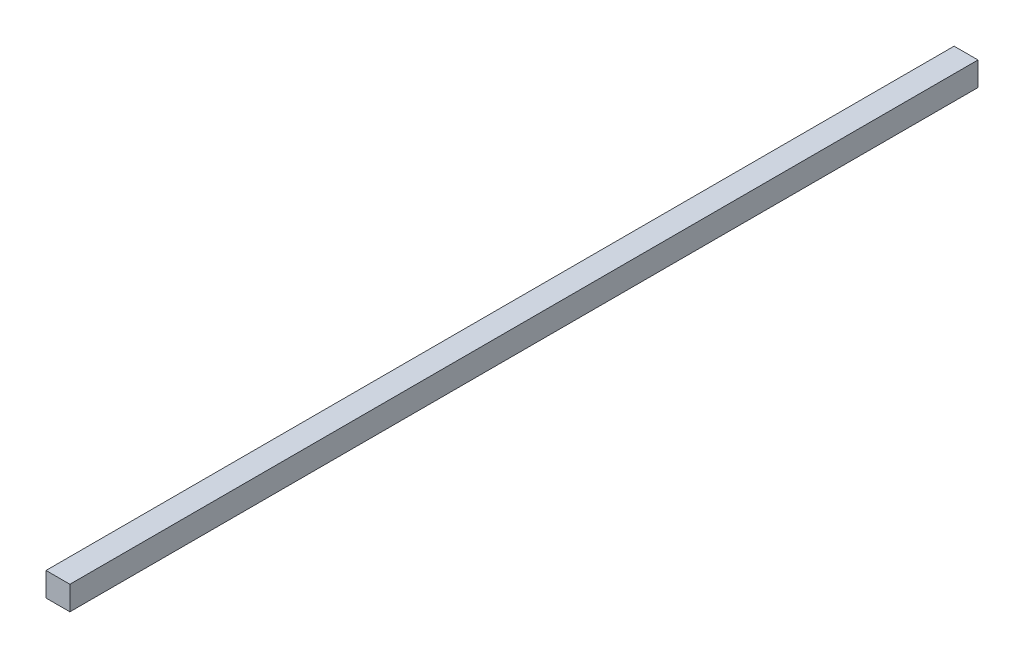
from build123d import *

# Parameters (mm, degrees)
SKETCH1_W           = 10
SKETCH1_H           = 10
BOSS_EXTRUDE1_DEPTH = 380


with BuildPart() as part:
    # Sketch1 → Boss-Extrude1 (new body)
    with BuildSketch(Plane.XY):
        Rectangle(SKETCH1_W, SKETCH1_H)
    extrude(amount=-BOSS_EXTRUDE1_DEPTH)


solid = part.part
